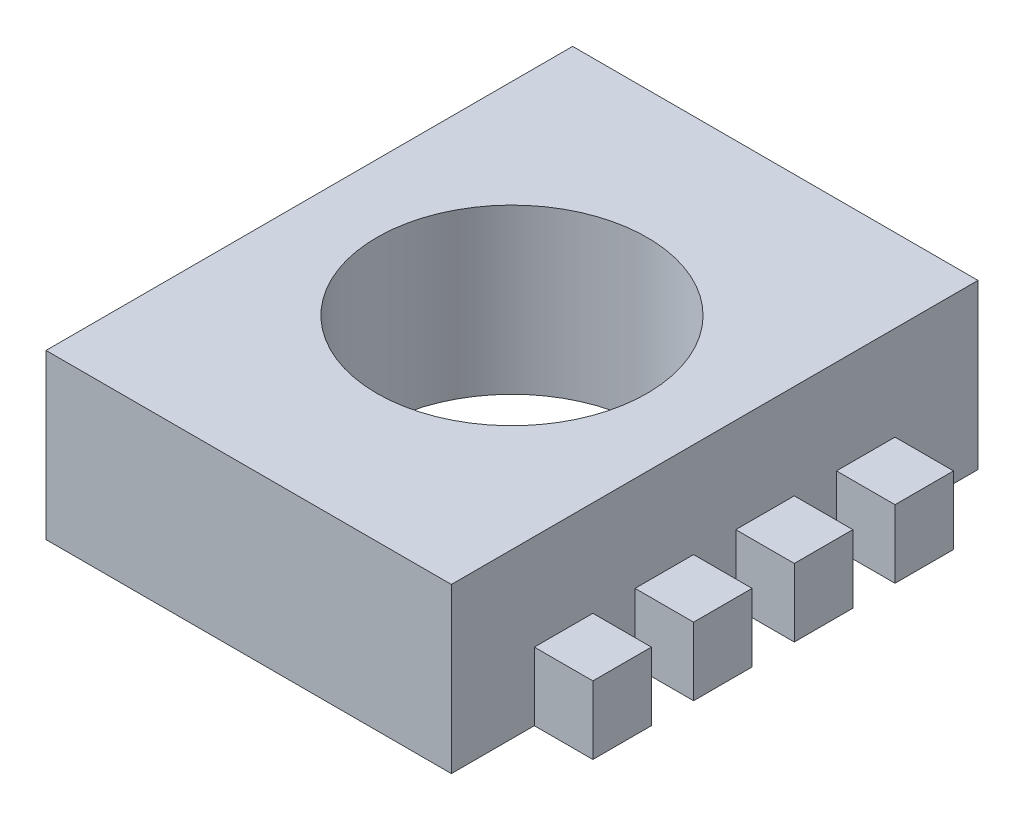
from build123d import *

# Parameters (mm, degrees)
SKETCH1_W           = 3.81
SKETCH1_H           = 4.95
SKETCH1_R           = 1.27
BOSS_EXTRUDE1_DEPTH = 1.54
SKETCH2_W           = 0.55
SKETCH2_H           = 0.64
BOSS_EXTRUDE2_DEPTH = 0.55
SKETCH4_W           = 0.55
SKETCH4_H           = 0.64
BOSS_EXTRUDE3_DEPTH = 0.55


with BuildPart() as part:
    # Sketch1 → Boss-Extrude1 (new body)
    with BuildSketch(Plane(origin=(0, 0, 0), x_dir=(1, 0, 0), z_dir=(0, 1, 0))):
        Rectangle(SKETCH1_W, SKETCH1_H)
        Circle(SKETCH1_R, mode=Mode.SUBTRACT)
    extrude(amount=BOSS_EXTRUDE1_DEPTH)

    # Sketch2 → Boss-Extrude2 (add)
    with BuildSketch(Plane(origin=(1.905, 0, 0), x_dir=(0, 0, -1), z_dir=(1, 0, 0))):
        with Locations((-1.42, 0.32)):
            Rectangle(SKETCH2_W, SKETCH2_H)
        with Locations((-0.473333333, 0.324745647)):
            Rectangle(SKETCH2_W, SKETCH2_H)
        with Locations((0.473333333, 0.329491295)):
            Rectangle(SKETCH2_W, SKETCH2_H)
        with Locations((1.42, 0.334236942)):
            Rectangle(SKETCH2_W, SKETCH2_H)
    extrude(amount=BOSS_EXTRUDE2_DEPTH)

    # Sketch4 → Boss-Extrude3 (add)
    with BuildSketch(Plane.ZY.offset(1.905)):
        with Locations((-1.42, 0.32)):
            Rectangle(SKETCH4_W, SKETCH4_H)
        with Locations((-0.47, 0.320104449)):
            Rectangle(SKETCH4_W, SKETCH4_H)
        with Locations((0.48, 0.320208897)):
            Rectangle(SKETCH4_W, SKETCH4_H)
        with Locations((1.43, 0.320313346)):
            Rectangle(SKETCH4_W, SKETCH4_H)
    extrude(amount=BOSS_EXTRUDE3_DEPTH)


solid = part.part
